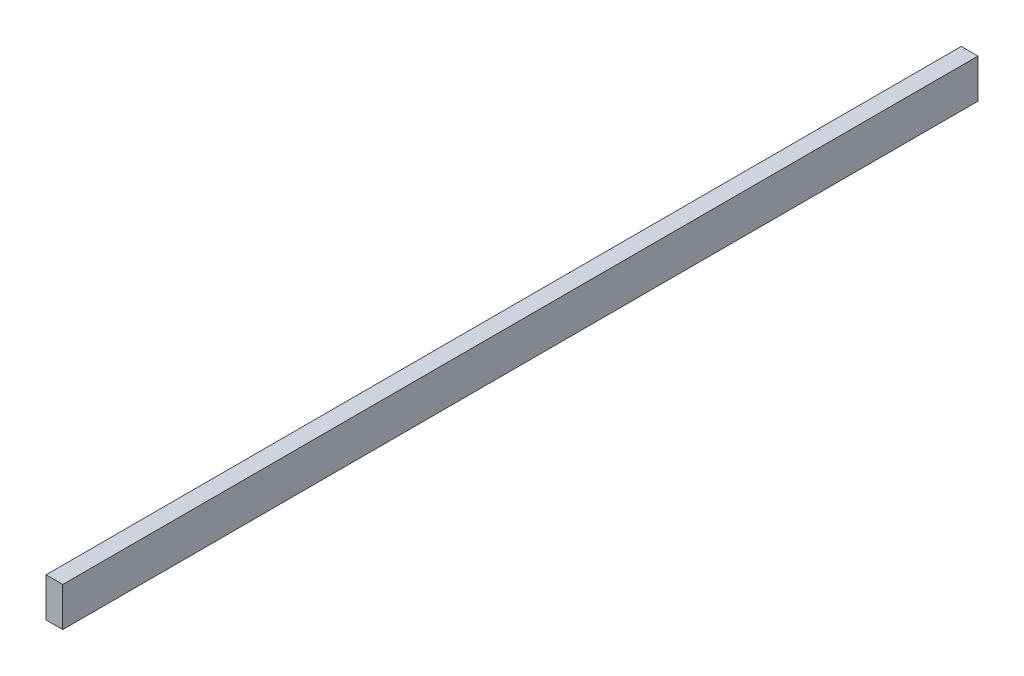
from build123d import *

# Parameters (mm, degrees)
SKETCH1_W           = 2082.8
SKETCH1_H           = 88.9
BOSS_EXTRUDE1_DEPTH = 38.1


with BuildPart() as part:
    # Sketch1 → Boss-Extrude1 (new body)
    with BuildSketch(Plane(origin=(0, 0, 0), x_dir=(0, 0, -1), z_dir=(1, 0, 0))):
        Rectangle(SKETCH1_W, SKETCH1_H)
    extrude(amount=BOSS_EXTRUDE1_DEPTH)


solid = part.part
